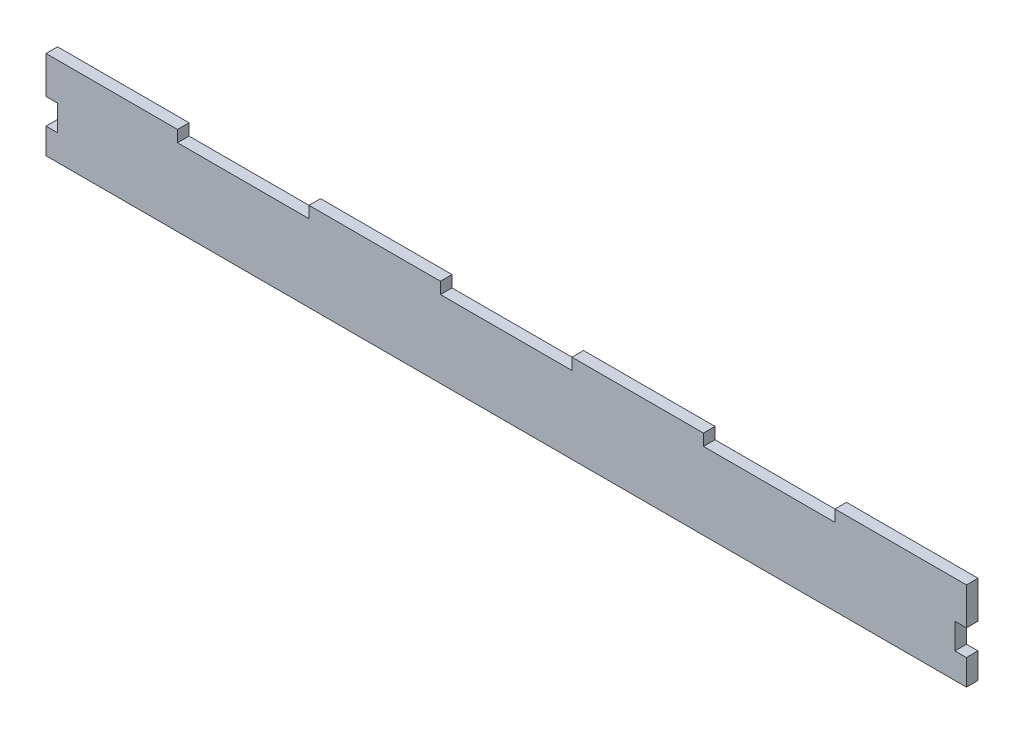
from build123d import *

# Parameters (mm, degrees)
SKETCH1_W               = 466
SKETCH1_H               = 126.5
BOSS_EXTRUDE1_DEPTH     = 6
SKETCH2_W               = 478
SKETCH2_H               = 6
BOSS_EXTRUDE2_DEPTH     = 40
CUT_EXTRUDE1_DEPTH      = 252.142514322
CUT_EXTRUDE1_DEPTH_BACK = 252.142514322
SKETCH1_2_W             = 466
SKETCH1_2_H             = 126.5
SKETCH2_4_W             = 68.285714286
SKETCH2_4_H             = 6
BOSS_EXTRUDE3_DEPTH     = 6
SKETCH3_W               = 6
SKETCH3_H               = 13.333333334
CUT_EXTRUDE2_DEPTH      = 6


with BuildPart() as part:
    # Sketch1 → Boss-Extrude1 (new body)
    with BuildSketch(Plane(origin=(0, 0, 0), x_dir=(1, 0, 0), z_dir=(0, 1, 0))):
        Rectangle(SKETCH1_W, SKETCH1_H)
    extrude(amount=BOSS_EXTRUDE1_DEPTH)

    # Sketch2 → Boss-Extrude2 (add)
    with BuildSketch(Plane(origin=(0, 6, 0), x_dir=(1, 0, 0), z_dir=(0, 1, 0))):
        with Locations((0, 66.25)):
            Rectangle(SKETCH2_W, SKETCH2_H)
    extrude(amount=-BOSS_EXTRUDE2_DEPTH)

    # Sketch1_2 → Cut-Extrude1 (cut, two sides: drawn at the far end of the back side and taken through both)
    with BuildSketch(Plane(origin=(0, 0, 0), x_dir=(1, 0, 0), z_dir=(0, 1, 0)).offset(-CUT_EXTRUDE1_DEPTH_BACK)):
        Rectangle(SKETCH1_2_W, SKETCH1_2_H)
    extrude(amount=CUT_EXTRUDE1_DEPTH + CUT_EXTRUDE1_DEPTH_BACK, mode=Mode.SUBTRACT)

    # Sketch2_4 → Boss-Extrude3 (add)
    with BuildSketch(Plane(origin=(0, 6, 0), x_dir=(1, 0, 0), z_dir=(0, 1, 0))):
        with Locations((204.857142857, 66.25)):
            Rectangle(SKETCH2_4_W, SKETCH2_4_H)
        with Locations((68.285714286, 66.25)):
            Rectangle(SKETCH2_4_W, SKETCH2_4_H)
        with Locations((-68.285714286, 66.25)):
            Rectangle(SKETCH2_4_W, SKETCH2_4_H)
        with Locations((-204.857142857, 66.25)):
            Rectangle(SKETCH2_4_W, SKETCH2_4_H)
    extrude(amount=BOSS_EXTRUDE3_DEPTH)

    # Sketch3 → Cut-Extrude2 (cut)
    with BuildSketch(Plane.XY.offset(-63.25)):
        with Locations((-236, -14)):
            Rectangle(SKETCH3_W, SKETCH3_H)
    cut_extrude2 = extrude(amount=-CUT_EXTRUDE2_DEPTH, mode=Mode.SUBTRACT)

    # Mirror1: Cut-Extrude2 across plane
    add(cut_extrude2.mirror(Plane(origin=(0, 0, 0), x_dir=(0, 0, 1), z_dir=(1, 0, 0))), mode=Mode.SUBTRACT)


solid = part.part
